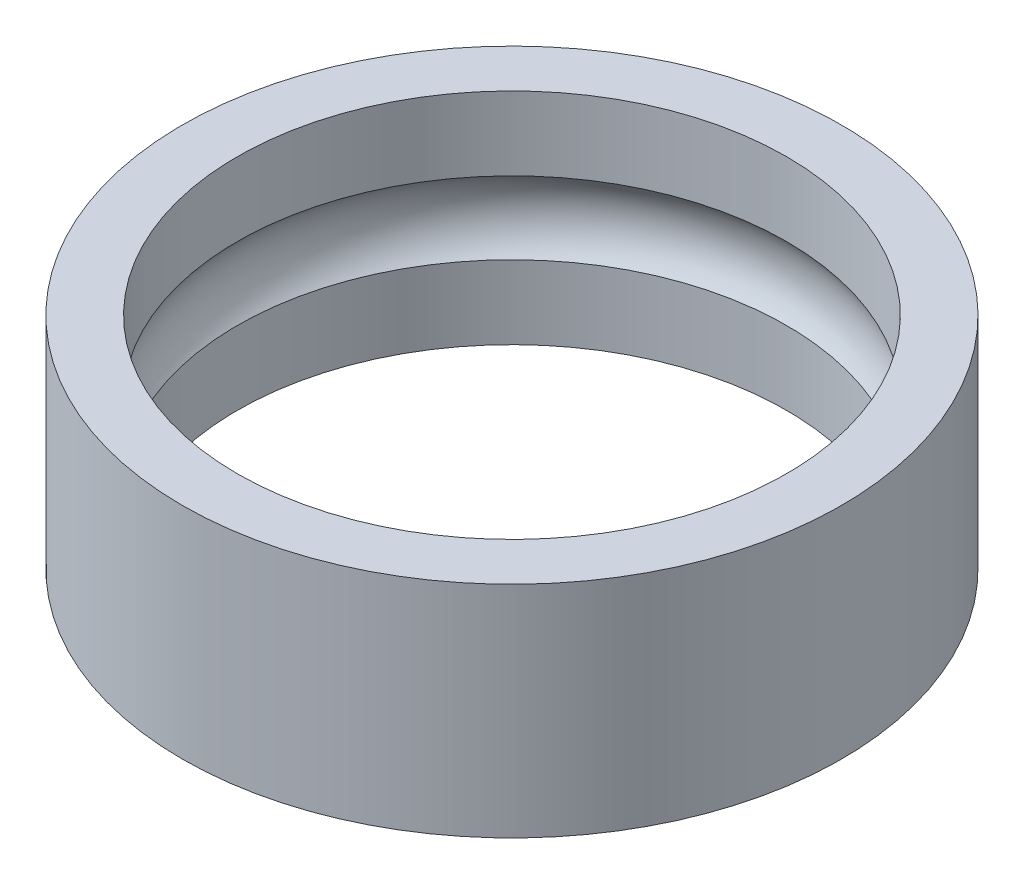
from build123d import *

# Parameters (mm, degrees)
DIAPROFILES_R         = 3
DIAPROFILES_R_2       = 2.5
DIAPROFILE_DEPTH      = 1
BEARINGPATHPROFILES_R = 0.5


with BuildPart() as part:
    # DiaProfileS → DiaProfile (new body, symmetric)
    with BuildSketch(Plane(origin=(0, 0, 0), x_dir=(1, 0, 0), z_dir=(0, 1, 0))):
        Circle(DIAPROFILES_R)
        Circle(DIAPROFILES_R_2, mode=Mode.SUBTRACT)
    extrude(amount=DIAPROFILE_DEPTH, both=True)

    # BearingPathProfileS → BearingPathProfile (revolve, cut)
    with BuildSketch(Plane.XY):
        with Locations((2.125, 0)):
            Circle(BEARINGPATHPROFILES_R)
    revolve(axis=Axis((0, 1, 0), (0, -1, 0)), mode=Mode.SUBTRACT)


solid = part.part
